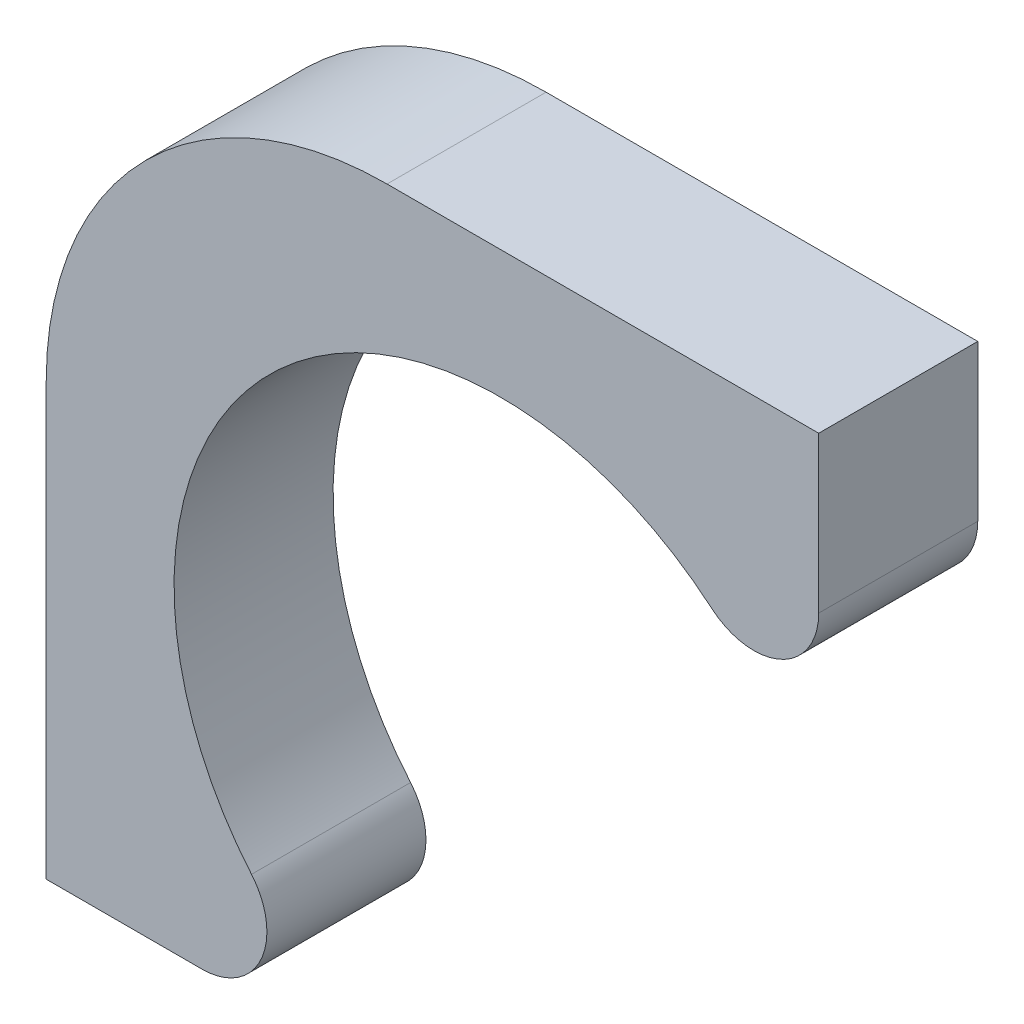
from build123d import *

# Parameters (mm, degrees)
SALIENTE_EXTRUIR1_DEPTH = 1.4


with BuildPart() as part:
    # Croquis1 → Saliente-Extruir1 (new body)
    with BuildSketch(Plane.XY):
        with BuildLine():
            Line((2.8, 4), (-1, 4))
            ThreePointArc((-1, 4), (-3.121320344, 3.121320344), (-4, 1))
            Line((-4, 1), (-4, -2.8))
            Line((-4, -2.8), (-2.628688939, -2.8))
            ThreePointArc((-2.628688939, -2.8), (-2.110290924, -2.468813544), (-2.192918912, -1.859228778))
            ThreePointArc((-2.192918912, -1.859228778), (-2.032931996, 2.032931996), (1.859228778, 2.192918912))
            ThreePointArc((1.859228778, 2.192918912), (2.468813544, 2.110290924), (2.8, 2.628688939))
            Line((2.8, 2.628688939), (2.8, 4))
        make_face()
    extrude(amount=SALIENTE_EXTRUIR1_DEPTH)


solid = part.part
